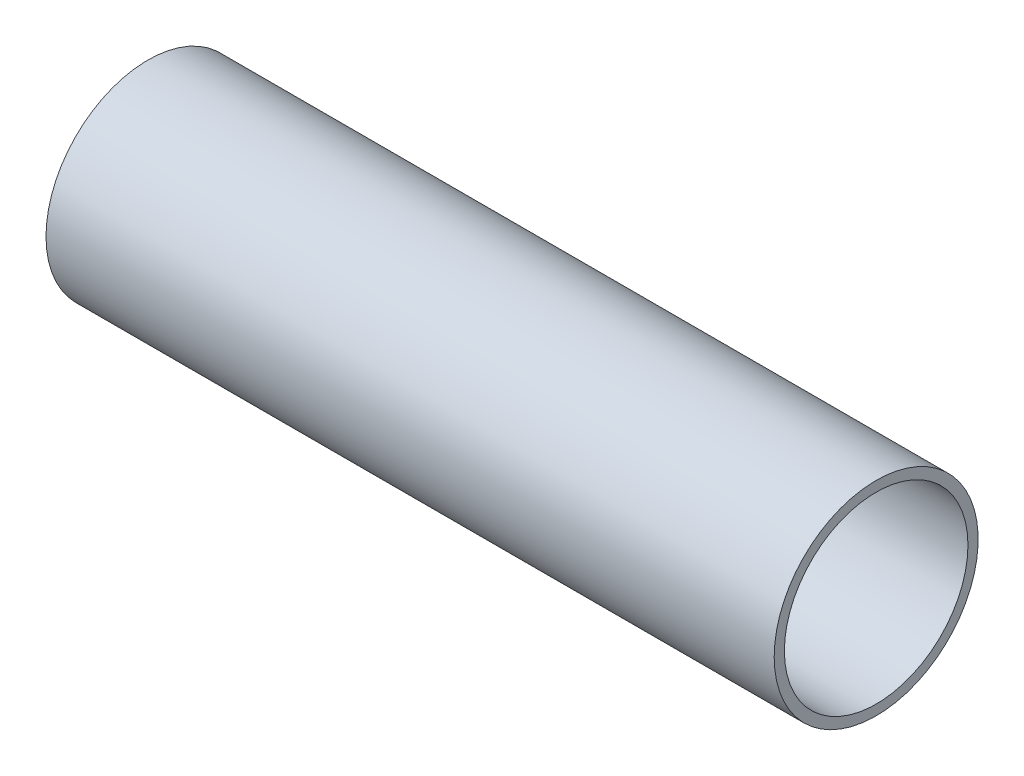
from build123d import *

# Parameters (mm, degrees)
SKETCH1_W = 113.3475
SKETCH1_H = 1.5875


with BuildPart() as part:
    # Sketch1 → Revolve1 (revolve)
    with BuildSketch(Plane(origin=(0, 0, 0), x_dir=(1, 0, 0), z_dir=(0, 1, 0))):
        with Locations((0, 15.08125)):
            Rectangle(SKETCH1_W, SKETCH1_H)
    revolve(axis=Axis((-135.471080774, 0, 0), (1, 0, 0)))


solid = part.part
